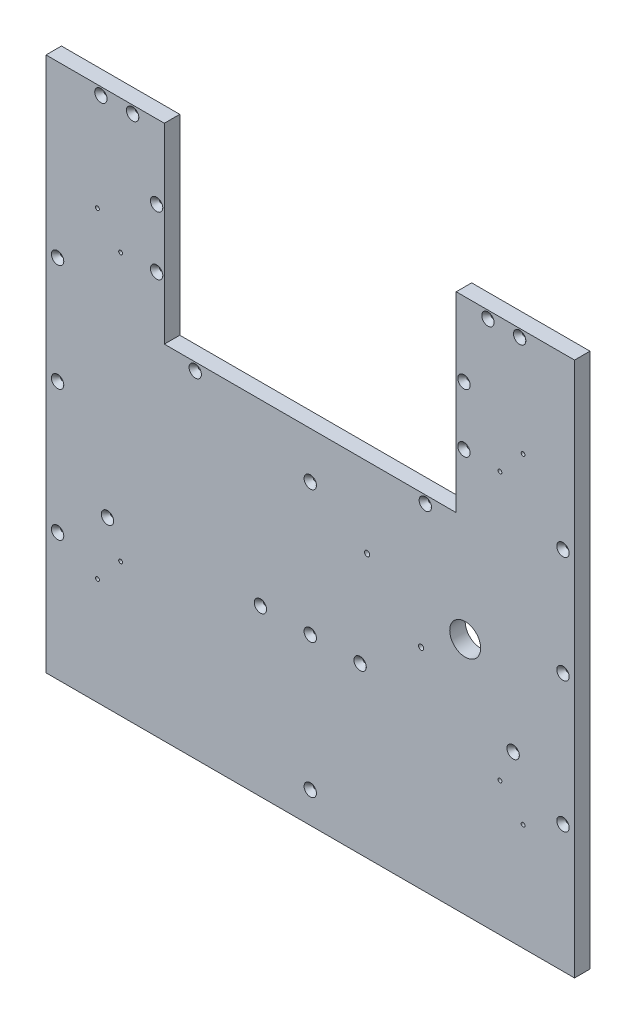
from build123d import *

# Parameters (mm, degrees)
BOSS_EXTRUDE1_DEPTH        = 12.7
HOLE1_D                    = 3.175
HOLE1_DEPTH                = 31.75
HOLE1_CSINK_D              = 10.16
HOLE1_CSINK_ANGLE          = 82
HOLE1_TIP                  = 0.953866233
HOLE2_D                    = 3.175
HOLE2_DEPTH                = 31.75
HOLE2_CSINK_D              = 10.16
HOLE2_CSINK_ANGLE          = 82
HOLE2_TIP                  = 0.953866233
F_1_1_DIAMETER_HOLE1_D     = 25.4
F_1_1_DIAMETER_HOLE1_DEPTH = 12.7
F_6_CLEARANCE_HOLE1_D      = 4.3053
F_6_CLEARANCE_HOLE1_DEPTH  = 12.7


with BuildPart() as part:
    # Sketch1 → Boss-Extrude1 (new body)
    with BuildSketch(Plane.XY):
        Polygon((341.304465963, 12.7), (244.004465963, 12.7), (244.004465963, -144.6), (124.004465969, -144.6), (124.004465969, -427.342121692), (341.304465963, -427.342121692), align=None)
    boss_extrude1 = extrude(amount=BOSS_EXTRUDE1_DEPTH)

    # Mirror1: Boss-Extrude1 across plane
    add(boss_extrude1.mirror(Plane(origin=(124.004465969, -144.6, 12.7), x_dir=(0, 0, 1), z_dir=(1, 0, 0))))

    # Hole1
    with Locations(Plane(origin=(124.004465969, 10.424290059, 12.7), x_dir=(-1, 0, 0), z_dir=(0, 0, 1))):
        with Locations((-207.774999994, 333.02141023), (-207.774999994, 225.48903684), (-207.774999994, 137.424290059), (-172.166666661, 4.074290059), (-146.083333327, 4.074290059), (-94.599999994, 161.374290059), (94.599999994, 161.374290059), (146.083333327, 4.074290059), (172.166666661, 4.074290059), (207.774999994, 137.424290059), (207.774999994, 225.48903684), (207.774999994, 333.02141023), (166.795833328, 301.970350905), (40.979166666, 301.970350905), (-40.979166666, 301.970350905), (-166.795833328, 301.970350905), (0, 193.124290059), (0, 301.970350905), (0, 412.366411751), (-126.349999994, 106.824290059), (-126.349999994, 58.624290059), (126.349999994, 58.624290059), (126.349999994, 106.824290059)):
            CounterSinkHole(HOLE1_D / 2, HOLE1_CSINK_D / 2, depth=HOLE1_DEPTH, counter_sink_angle=HOLE1_CSINK_ANGLE)
            with Locations((0, 0, -(HOLE1_DEPTH + HOLE1_TIP / 2))):  # 118° drill point
                Cone(0, HOLE1_D / 2, HOLE1_TIP, mode=Mode.SUBTRACT)

    # Hole2
    with Locations(Plane(origin=(124.004465969, 10.424290059, 0), x_dir=(1, 0, 0), z_dir=(0, 0, -1))):
        with Locations((-155.949999994, 107.734820482), (155.949999994, 107.734820482), (155.949999994, 327.755881328), (174.999999994, 85.732714397), (174.999999994, 349.757987412), (-174.999999994, 349.757987412), (-174.999999994, 85.732714397), (-155.949999994, 327.755881328)):
            CounterSinkHole(HOLE2_D / 2, HOLE2_CSINK_D / 2, depth=HOLE2_DEPTH, counter_sink_angle=HOLE2_CSINK_ANGLE)
            with Locations((0, 0, -(HOLE2_DEPTH + HOLE2_TIP / 2))):  # 118° drill point
                Cone(0, HOLE2_D / 2, HOLE2_TIP, mode=Mode.SUBTRACT)

    # 1 (1) Diameter Hole1
    with Locations(Plane(origin=(0, 0, 0), x_dir=(-1, 0, 0), z_dir=(0, 0, -1))):
        with Locations((-251.379465963, -231.121997256)):
            Hole(F_1_1_DIAMETER_HOLE1_D / 2, depth=F_1_1_DIAMETER_HOLE1_DEPTH)

    # #6 Clearance Hole1
    with Locations(Plane(origin=(0, 0, 0), x_dir=(-1, 0, 0), z_dir=(0, 0, -1))):
        with Locations((-215.152465963, -254.856060846), (-170.702465963, -210.406060846)):
            Hole(F_6_CLEARANCE_HOLE1_D / 2, depth=F_6_CLEARANCE_HOLE1_DEPTH)


solid = part.part
